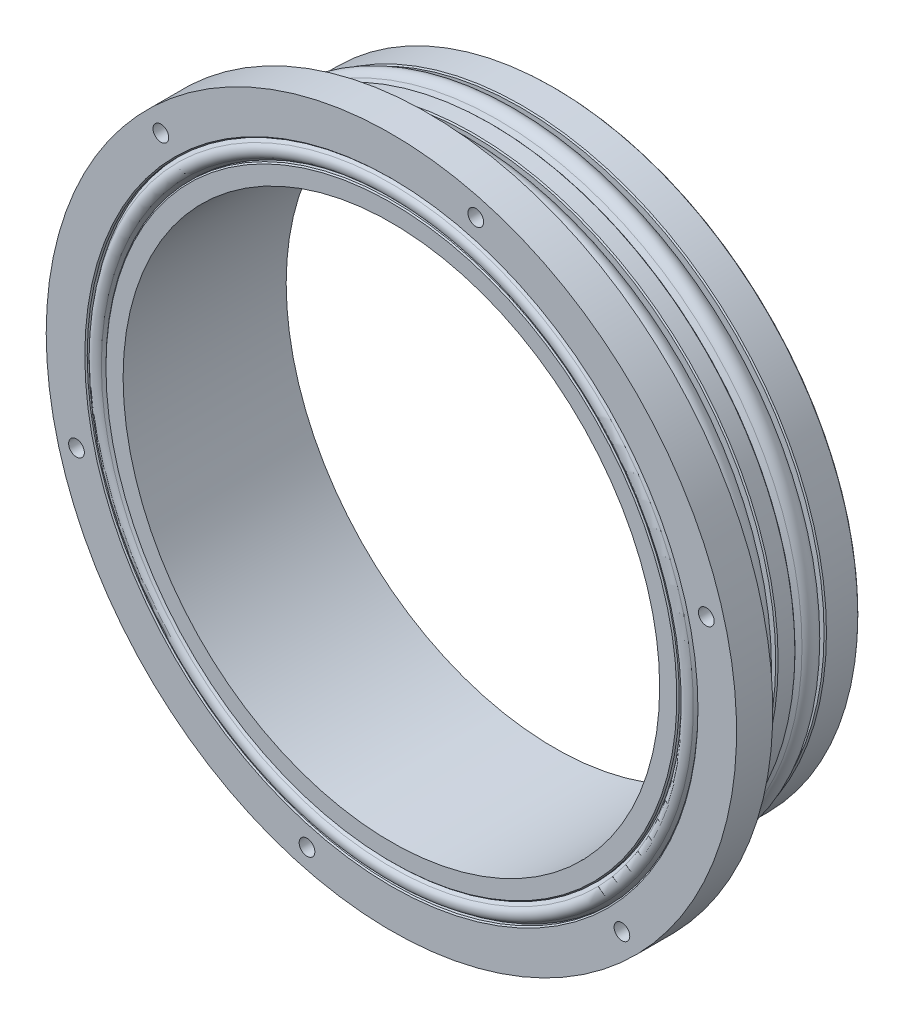
from build123d import *

# Parameters (mm, degrees)
HOLE_WIZARD_2_6_2_6_1_D     = 2.6
HOLE_WIZARD_2_6_2_6_1_DEPTH = 4
HOLE_WIZARD_2_6_2_6_2_D     = 2.6
HOLE_WIZARD_2_6_2_6_2_DEPTH = 6.526692879
HOLE_WIZARD_M80_1_D         = 88.838
HOLE_WIZARD_M80_1_DEPTH     = 27
CHAMFER_1_SIZE              = 0.2


with BuildPart() as part:
    # 草图1 → 旋转1 (revolve)
    with BuildSketch(Plane.XZ):
        with BuildLine():
            Line((47.2599, 27), (0, 27))
            Line((0, 27), (0, 0))
            Line((0, 0), (50.419, 0))
            Line((50.419, 0), (50.419, 5.587))
            Line((50.419, 5.587), (49.04105, 5.587))
            Line((49.04105, 5.587), (50.431651886, 6.547495355))
            ThreePointArc((50.431651886, 6.547495355), (51.1937, 8), (50.431651886, 9.452504645))
            Line((50.431651886, 9.452504645), (49.04105, 10.413))
            Line((49.04105, 10.413), (50.419, 10.413))
            Line((50.419, 10.413), (50.419, 13.587))
            Line((50.419, 13.587), (49.04105, 13.587))
            Line((49.04105, 13.587), (50.431651886, 14.547495355))
            ThreePointArc((50.431651886, 14.547495355), (51.1937, 16), (50.431651886, 17.452504645))
            Line((50.431651886, 17.452504645), (49.04105, 18.413))
            Line((49.04105, 18.413), (50.419, 18.413))
            Line((50.419, 18.413), (50.419, 21))
            Line((50.419, 21), (57.15, 21))
            Line((57.15, 21), (57.15, 27))
            Line((57.15, 27), (50.5587, 27))
            Line((50.5587, 27), (50.5587, 26.279170235))
            Line((50.5587, 26.279170235), (50.013761564, 27.01901462))
            ThreePointArc((50.013761564, 27.01901462), (49.0093, 27.526692879), (48.004838436, 27.01901462))
            Line((48.004838436, 27.01901462), (47.4599, 26.279170235))
            Line((47.4599, 26.279170235), (47.4599, 26.8))
            Line((47.4599, 26.8), (47.2599, 27))
        make_face()
    revolve(axis=Axis((0, 0, 27.526692879), (0, 0, -1)))

    # Ø2.6 (2.6) 直径孔1
    with Locations(Plane(origin=(0, 0, 0), x_dir=(-1, 0, 0), z_dir=(0, 0, -1))):
        with Locations((-33.226947648, 33.226947648), (33.226947648, 33.226947648), (33.226947648, -33.226947648), (-33.226947648, -33.226947648)):
            Hole(HOLE_WIZARD_2_6_2_6_1_D / 2, depth=HOLE_WIZARD_2_6_2_6_1_DEPTH)

    # Ø2.6 (2.6) 直径孔2
    with Locations(Plane(origin=(0, 0, 21), x_dir=(-1, 0, 0), z_dir=(0, 0, -1))):
        with Locations((38.166088515, 38.166088515), (-13.969757959, 52.135846474), (-52.135846474, 13.969757959), (-38.166088515, -38.166088515), (13.969757959, -52.135846474), (52.135846474, -13.969757959)):
            Hole(HOLE_WIZARD_2_6_2_6_2_D / 2, depth=HOLE_WIZARD_2_6_2_6_2_DEPTH)

    # M80 间隙孔1
    with Locations(Plane.XY.offset(27)):
        with Locations((0, 0)):
            Hole(HOLE_WIZARD_M80_1_D / 2, depth=HOLE_WIZARD_M80_1_DEPTH)

    # 倒角1
    chamfer_1_edges = [part.edges().sort_by_distance(p)[0] for p in [
        (-50.419, 0, 0),
        (-50.419, 0, 5.587),
        (-50.419, 0, 10.413),
        (-50.419, 0, 13.587),
        (-50.419, 0, 18.413),
        (-50.5587, 0, 27),
    ]]
    chamfer(chamfer_1_edges, length=CHAMFER_1_SIZE)


solid = part.part
